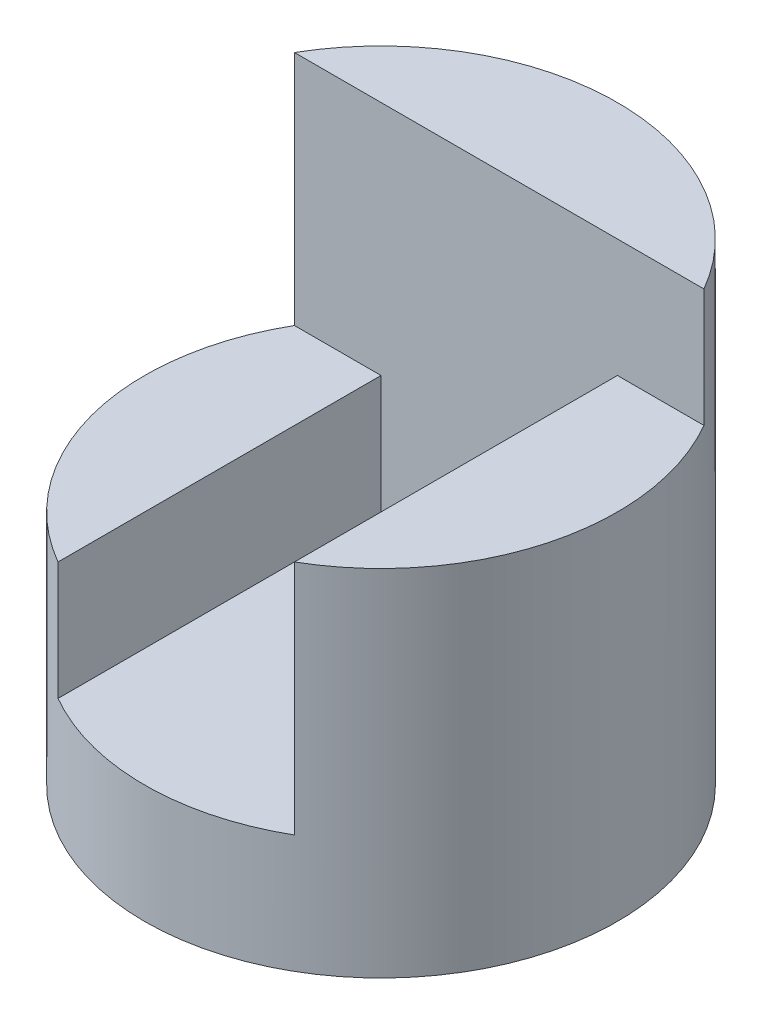
from build123d import *

# Parameters (mm, degrees)
SKETCH1_R               = 2
BOSS_EXTRUDE1_DEPTH     = 4
CUT_EXTRUDE1_DEPTH      = 3
CUT_EXTRUDE1_DEPTH_BACK = 1
SKETCH3_W               = 1
SKETCH3_H               = 1
CUT_EXTRUDE2_DEPTH      = 11
CUT_EXTRUDE2_DEPTH_BACK = 1


with BuildPart() as part:
    # Sketch1 → Boss-Extrude1 (new body)
    with BuildSketch(Plane(origin=(0, 0, 0), x_dir=(1, 0, 0), z_dir=(0, 1, 0))):
        Circle(SKETCH1_R)
    extrude(amount=BOSS_EXTRUDE1_DEPTH)

    # Sketch2 → Cut-Extrude1 (cut, two sides)
    with BuildSketch(Plane.XY) as cut_extrude1_sk:
        Polygon((-2, 4), (2, 4), (2, 3), (1, 3), (1, 1), (-1, 1), (-1, 3), (-2, 3), align=None)
    extrude(amount=CUT_EXTRUDE1_DEPTH, mode=Mode.SUBTRACT)
    extrude(cut_extrude1_sk.sketch, amount=-CUT_EXTRUDE1_DEPTH_BACK, mode=Mode.SUBTRACT)

    # Sketch3 → Cut-Extrude2 (cut, two sides)
    with BuildSketch(Plane.XY) as cut_extrude2_sk:
        with Locations((-1.5, 2.5)):
            Rectangle(SKETCH3_W, SKETCH3_H)
    extrude(amount=CUT_EXTRUDE2_DEPTH, mode=Mode.SUBTRACT)
    extrude(cut_extrude2_sk.sketch, amount=-CUT_EXTRUDE2_DEPTH_BACK, mode=Mode.SUBTRACT)


solid = part.part
